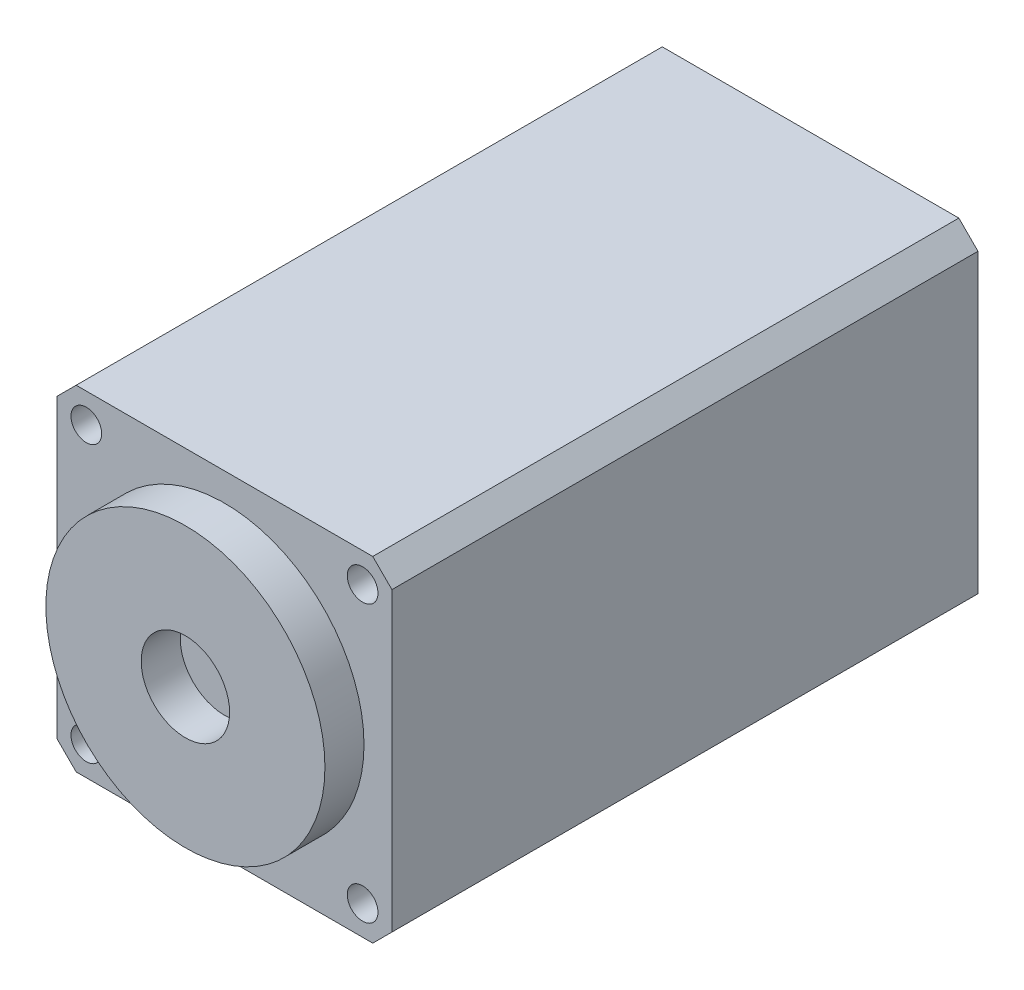
from build123d import *

# Parameters (mm, degrees)
SKETCH1_R           = 2.75
BOSS_EXTRUDE1_DEPTH = 105
SKETCH2_R           = 25
SKETCH2_R_2         = 7.920218335
BOSS_EXTRUDE2_DEPTH = 7
SKETCH3_R           = 25
SKETCH3_R_2         = 7
CUT_EXTRUDE1_DEPTH  = 6
SKETCH3_2_R         = 7
CUT_EXTRUDE2_DEPTH  = 34


with BuildPart() as part:
    # Sketch1 → Boss-Extrude1 (new body)
    with BuildSketch(Plane.XY):
        Polygon((-30, 26.568542495), (-30, -26.568542495), (-26.568542495, -30), (26.568542495, -30), (30, -26.568542495), (30, 26.568542495), (26.568542495, 30), (-26.568542495, 30), align=None)
        with Locations((-24.748737342, -24.748737342)):
            Circle(SKETCH1_R, mode=Mode.SUBTRACT)
        with Locations((24.748737342, -24.748737342)):
            Circle(SKETCH1_R, mode=Mode.SUBTRACT)
        with Locations((-24.748737342, 24.748737342)):
            Circle(SKETCH1_R, mode=Mode.SUBTRACT)
        with Locations((24.748737342, 24.748737342)):
            Circle(SKETCH1_R, mode=Mode.SUBTRACT)
    extrude(amount=BOSS_EXTRUDE1_DEPTH)

    # Sketch2 → Boss-Extrude2 (add)
    with BuildSketch(Plane.XY.offset(105)):
        Circle(SKETCH2_R)
        Circle(SKETCH2_R_2, mode=Mode.SUBTRACT)
    extrude(amount=BOSS_EXTRUDE2_DEPTH)

    # Sketch3 → Cut-Extrude1 (cut)
    with BuildSketch(Plane(origin=(0, 0, 0), x_dir=(-1, 0, 0), z_dir=(0, 0, -1))):
        Circle(SKETCH3_R)
        Circle(SKETCH3_R_2, mode=Mode.SUBTRACT)
    extrude(amount=-CUT_EXTRUDE1_DEPTH, mode=Mode.SUBTRACT)

    # Sketch3_2 → Cut-Extrude2 (cut)
    with BuildSketch(Plane(origin=(0, 0, 0), x_dir=(-1, 0, 0), z_dir=(0, 0, -1))):
        Circle(SKETCH3_2_R)
    extrude(amount=-CUT_EXTRUDE2_DEPTH, mode=Mode.SUBTRACT)


solid = part.part
